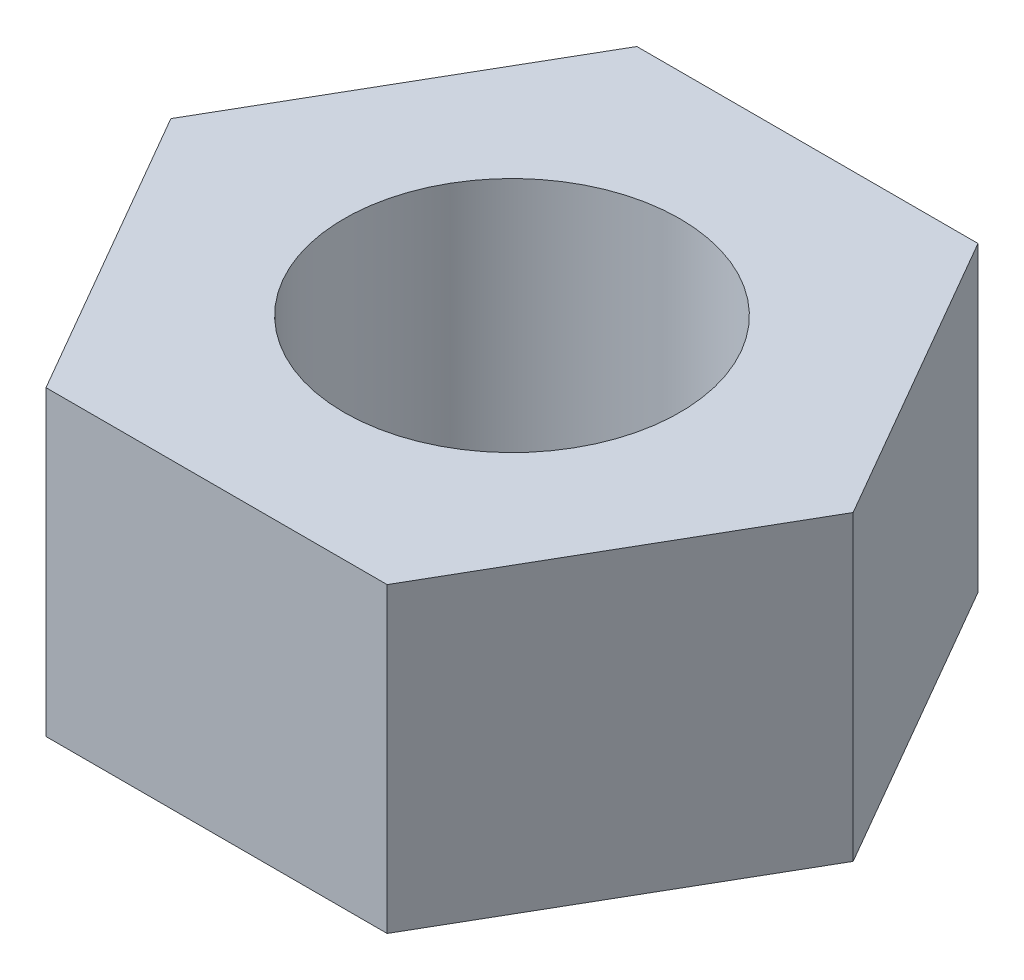
from build123d import *

# Parameters (mm, degrees)
SKETCH1_R           = 2.5
BOSS_EXTRUDE1_DEPTH = 4.5


with BuildPart() as part:
    # Sketch1 → Boss-Extrude1 (new body)
    with BuildSketch(Plane(origin=(0, 0, 0), x_dir=(1, 0, 0), z_dir=(0, 1, 0))):
        Polygon((2.540341184, -4.4), (5.080682369, 0), (2.540341184, 4.4), (-2.540341184, 4.4), (-5.080682369, 0), (-2.540341184, -4.4), align=None)
        Circle(SKETCH1_R, mode=Mode.SUBTRACT)
    extrude(amount=BOSS_EXTRUDE1_DEPTH)


solid = part.part
